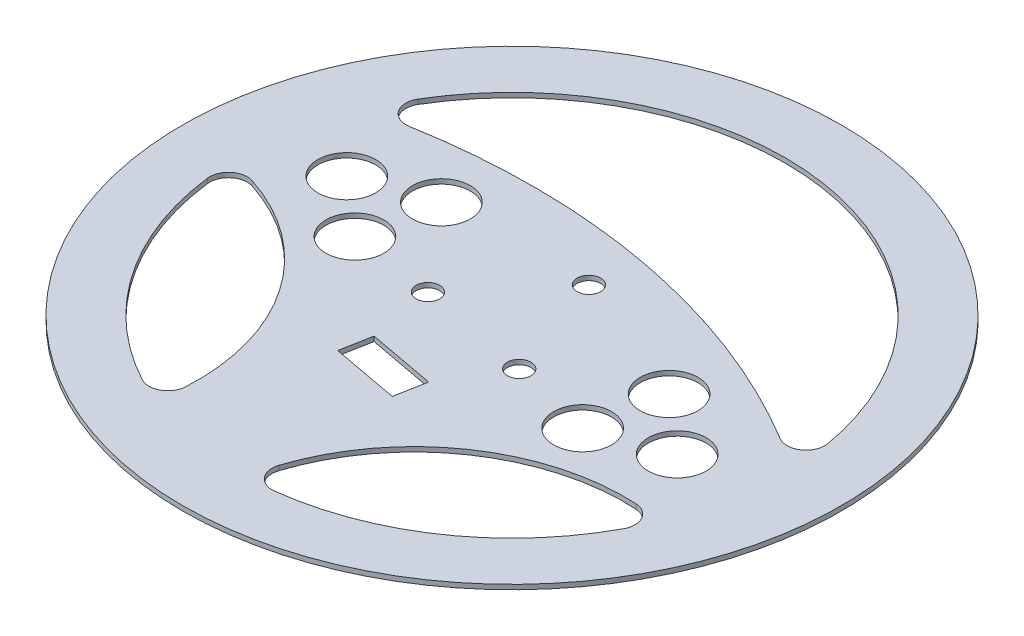
from build123d import *

# Parameters (mm, degrees)
SKETCH1_R           = 111.125
SKETCH1_R_2         = 3.96875
SKETCH1_R_3         = 9.75
BOSS_EXTRUDE1_DEPTH = 1.5875


with BuildPart() as part:
    # Sketch1 → Boss-Extrude1 (new body)
    with BuildSketch(Plane(origin=(0, 0, 0), x_dir=(1, 0, 0), z_dir=(0, 1, 0))):
        with Locations((0, 2.067110037)):
            Circle(SKETCH1_R)
        with Locations((4.071636725, 23.915963539)):
            Circle(SKETCH1_R_2, mode=Mode.SUBTRACT)
        with Locations((-20.957480539, -5.331175876)):
            Circle(SKETCH1_R_2, mode=Mode.SUBTRACT)
        with Locations((16.885843815, -12.383457553)):
            Circle(SKETCH1_R_2, mode=Mode.SUBTRACT)
        with Locations((-44.897615706, 23.149190197)):
            Circle(SKETCH1_R_3, mode=Mode.SUBTRACT)
        with Locations((-49.477634519, -1.427697882)):
            Circle(SKETCH1_R_3, mode=Mode.SUBTRACT)
        with Locations((-68.471834536, 14.827158799)):
            Circle(SKETCH1_R_3, mode=Mode.SUBTRACT)
        with Locations((68.471834536, -10.692938726)):
            Circle(SKETCH1_R_3, mode=Mode.SUBTRACT)
        with Locations((44.897615706, -19.014970124)):
            Circle(SKETCH1_R_3, mode=Mode.SUBTRACT)
        with Locations((49.477634519, 5.561917956)):
            Circle(SKETCH1_R_3, mode=Mode.SUBTRACT)
        Polygon((3.519990025, -41.816901652), (5.443597926, -31.494608658), (-17.167139107, -27.28099135), (-19.090747008, -37.603284344), align=None, mode=Mode.SUBTRACT)
        with BuildLine():
            ThreePointArc((90.719240331, 17.809570412), (16.868209288, 92.583788834), (-78.959268715, 49.429959498))
            ThreePointArc((-78.959268715, 49.429959498), (-78.745756198, 42.56506275), (-72.411496849, 39.909963234))
            ThreePointArc((-72.411496849, 39.909963234), (6.979948671, 39.52228747), (81.18188186, 11.287113924))
            ThreePointArc((81.18188186, 11.287113924), (88.04732163, 11.482387358), (90.719240331, 17.809570412))
        make_face(mode=Mode.SUBTRACT)
        with BuildLine():
            ThreePointArc((-34.133508794, -73.846482708), (-46.481955973, -29.811909239), (-83.112792301, -2.431083134))
            ThreePointArc((-83.112792301, -2.431083134), (-89.116651342, -3.572720267), (-91.376738817, -9.250894562))
            ThreePointArc((-91.376738817, -9.250894562), (-75.932582562, -50.010222177), (-43.472216603, -79.099213082))
            ThreePointArc((-43.472216603, -79.099213082), (-37.361105633, -79.036114425), (-34.133508794, -73.846482708))
        make_face(mode=Mode.SUBTRACT)
        with BuildLine():
            ThreePointArc((4.498193171, -81.045682265), (31.879019276, -44.414845936), (75.913592744, -32.066398757))
            ThreePointArc((75.913592744, -32.066398757), (81.103224462, -35.293995597), (81.166323119, -41.405106566))
            ThreePointArc((81.166323119, -41.405106566), (52.077332214, -73.865472525), (11.318004599, -89.309628781))
            ThreePointArc((11.318004599, -89.309628781), (5.639830304, -87.049541305), (4.498193171, -81.045682265))
        make_face(mode=Mode.SUBTRACT)
    extrude(amount=BOSS_EXTRUDE1_DEPTH)


solid = part.part
